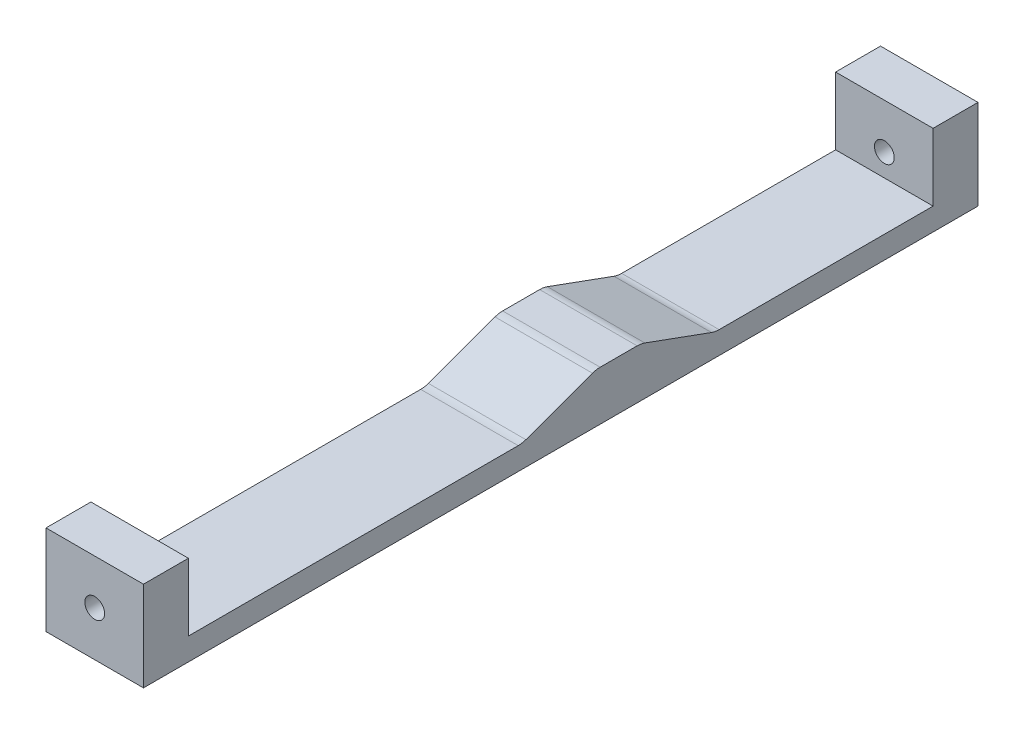
from build123d import *

# Parameters (mm, degrees)
SKETCH1_W           = 13.7795
SKETCH1_H           = 117.97300002
BOSS_EXTRUDE1_DEPTH = 3.175
SKETCH5_W           = 13.7795
SKETCH5_H           = 9.525
BOSS_EXTRUDE2_DEPTH = 6.35
SKETCH4_R           = 1.399999994
CUT_EXTRUDE1_DEPTH  = 118.97300002
BOSS_EXTRUDE3_DEPTH = 13.7795
FILLET1_R           = 3.175


with BuildPart() as part:
    # Sketch1 → Boss-Extrude1 (new body)
    with BuildSketch(Plane(origin=(0, 0, 0), x_dir=(1, 0, 0), z_dir=(0, 1, 0))):
        Rectangle(SKETCH1_W, SKETCH1_H)
    extrude(amount=BOSS_EXTRUDE1_DEPTH)

    # Sketch5 → Boss-Extrude2 (add)
    with BuildSketch(Plane.XY.offset(58.98650001)):
        with Locations((0, 7.9375)):
            Rectangle(SKETCH5_W, SKETCH5_H)
    boss_extrude2 = extrude(amount=-BOSS_EXTRUDE2_DEPTH)

    # Mirror1: Boss-Extrude2 across plane
    add(boss_extrude2.mirror(Plane.XY))

    # Sketch4 → Cut-Extrude1 (cut, through all)
    with BuildSketch(Plane.XY.offset(58.98650001)):
        with Locations((0, 6.35)):
            Circle(SKETCH4_R)
    extrude(amount=-CUT_EXTRUDE1_DEPTH, mode=Mode.SUBTRACT)

    # Sketch6 → Boss-Extrude3 (add)
    with BuildSketch(Plane.ZY.offset(6.88975)):
        Polygon((-11.36150001, 6.985), (-5.01150001, 6.985), (5.456388958, 3.175), (-21.829388978, 3.175), align=None)
    extrude(amount=-BOSS_EXTRUDE3_DEPTH)

    # Fillet1
    fillet1_edges = [part.edges().sort_by_distance(p)[0] for p in [
        (0, 3.175, -21.829388978),
        (0, 6.985, -11.36150001),
        (0, 6.985, -5.01150001),
        (0, 3.175, 5.456388958),
    ]]
    fillet(fillet1_edges, radius=FILLET1_R)


solid = part.part
